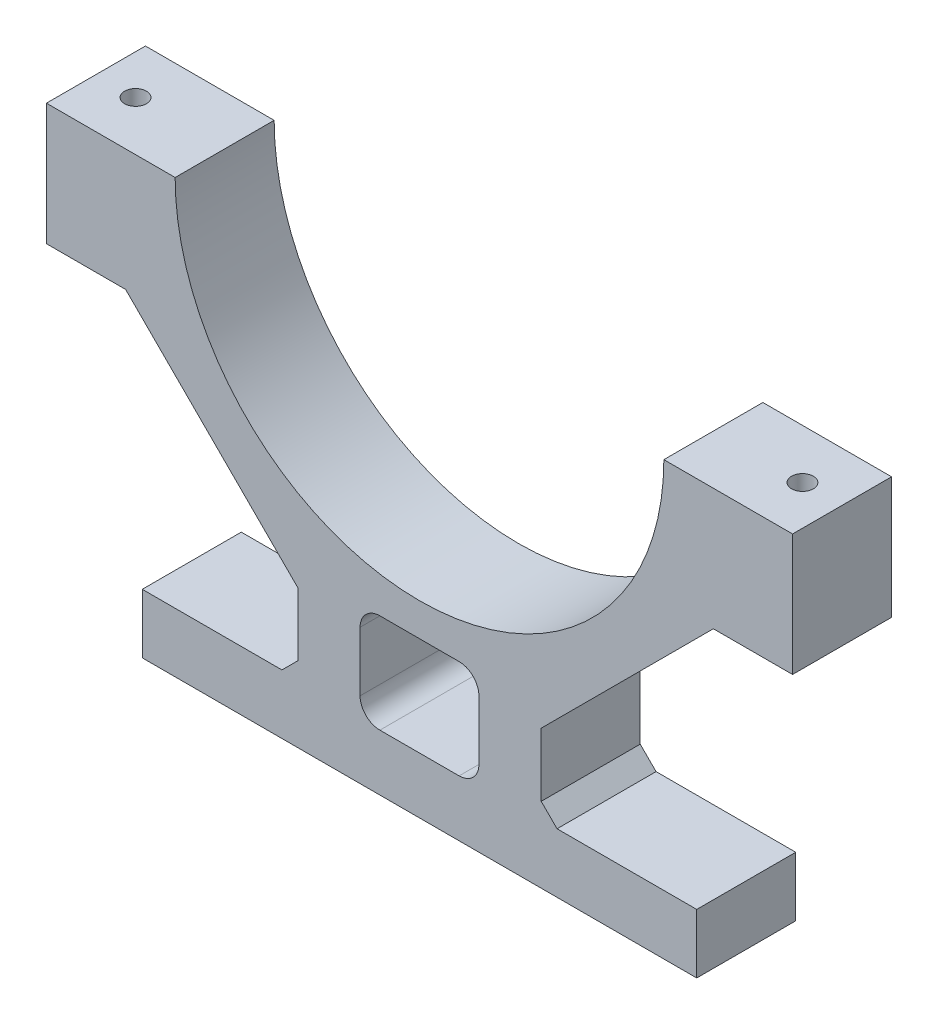
from build123d import *

# Parameters (mm, degrees)
BASE_GEO_DEPTH                  = 15.875
SKETCH2_R                       = 3.5000057
BOLT_HOLE_DEPTH                 = 40.033000837
SKETCH3_R                       = 5.7500012
NUT_AND_BOLT_HEAD_CUTOUTS_DEPTH = 33.953001
SKETCH5_W                       = 177.8
SKETCH5_H                       = 19.05
BOSS_EXTRUDE1_DEPTH             = 31.75
CUT_EXTRUDE1_DEPTH              = 32.75
CHAMFER1_SIZE                   = 5.08


with BuildPart() as part:
    # Sketch1 → base geo (new body, symmetric)
    with BuildSketch(Plane.XY):
        with BuildLine():
            ThreePointArc((-78.359, 0), (0, -78.359), (78.359, 0))
            Line((78.359, 0), (119.634, 0))
            Line((119.634, 0), (119.634, -39.033000837))
            Line((119.634, -39.033000837), (94.234, -39.033000837))
            Line((94.234, -39.033000837), (39.033000837, -94.234))
            Line((39.033000837, -94.234), (39.033000837, -119.634))
            Line((39.033000837, -119.634), (-39.033000837, -119.634))
            Line((-39.033000837, -119.634), (-39.033000837, -94.234))
            Line((-39.033000837, -94.234), (-94.234, -39.033000837))
            Line((-94.234, -39.033000837), (-119.634, -39.033000837))
            Line((-119.634, -39.033000837), (-119.634, 0))
            Line((-119.634, 0), (-78.359, 0))
        make_face()
    extrude(amount=BASE_GEO_DEPTH, both=True)

    # Sketch2 → bolt hole (cut, through all)
    with BuildSketch(Plane.XZ.offset(39.033000837)):
        with Locations((-106.934, 0)):
            Circle(SKETCH2_R)
    bolt_hole = extrude(amount=-BOLT_HOLE_DEPTH, mode=Mode.SUBTRACT)

    # bolt hole mirrored: bolt hole across plane
    add(bolt_hole.mirror(Plane(origin=(0, 0, 0), x_dir=(0, 0, 1), z_dir=(1, 0, 0))), mode=Mode.SUBTRACT)

    # Sketch3 → nut and bolt head cutouts (cut)
    with BuildSketch(Plane.XZ.offset(39.033000837)):
        with Locations((-106.934, 0)):
            Circle(SKETCH3_R)
        Polygon((112.1840022, -3.031090183), (112.1840022, 3.031090183), (106.934, 6.062180367), (101.6839978, 3.031090183), (101.6839978, -3.031090183), (106.934, -6.062180367), align=None)
    extrude(amount=-NUT_AND_BOLT_HEAD_CUTOUTS_DEPTH, mode=Mode.SUBTRACT)

    # Sketch5 → Boss-Extrude1 (add)
    with BuildSketch(Plane(origin=(0, 0, -15.875), x_dir=(-1, 0, 0), z_dir=(0, 0, -1))):
        with Locations((0, -129.159)):
            Rectangle(SKETCH5_W, SKETCH5_H)
    extrude(amount=-BOSS_EXTRUDE1_DEPTH)

    # Sketch6 → Cut-Extrude1 (cut, through all)
    with BuildSketch(Plane(origin=(0, 0, -15.875), x_dir=(-1, 0, 0), z_dir=(0, 0, -1))):
        with BuildLine():
            Line((12.7, -120.65), (-12.7, -120.65))
            ThreePointArc((-12.7, -120.65), (-17.190128061, -118.790128061), (-19.05, -114.3))
            Line((-19.05, -114.3), (-19.05, -95.25))
            ThreePointArc((-19.05, -95.25), (-17.190128061, -90.759871939), (-12.7, -88.9))
            Line((-12.7, -88.9), (12.7, -88.9))
            ThreePointArc((12.7, -88.9), (17.190128061, -90.759871939), (19.05, -95.25))
            Line((19.05, -95.25), (19.05, -114.3))
            ThreePointArc((19.05, -114.3), (17.190128061, -118.790128061), (12.7, -120.65))
        make_face()
    extrude(amount=-CUT_EXTRUDE1_DEPTH, mode=Mode.SUBTRACT)

    # Chamfer1
    chamfer1_edges = [part.edges().sort_by_distance(p)[0] for p in [
        (39.033000837, -119.634, 0),
        (-39.033000837, -119.634, 0),
    ]]
    chamfer(chamfer1_edges, length=CHAMFER1_SIZE)


solid = part.part
